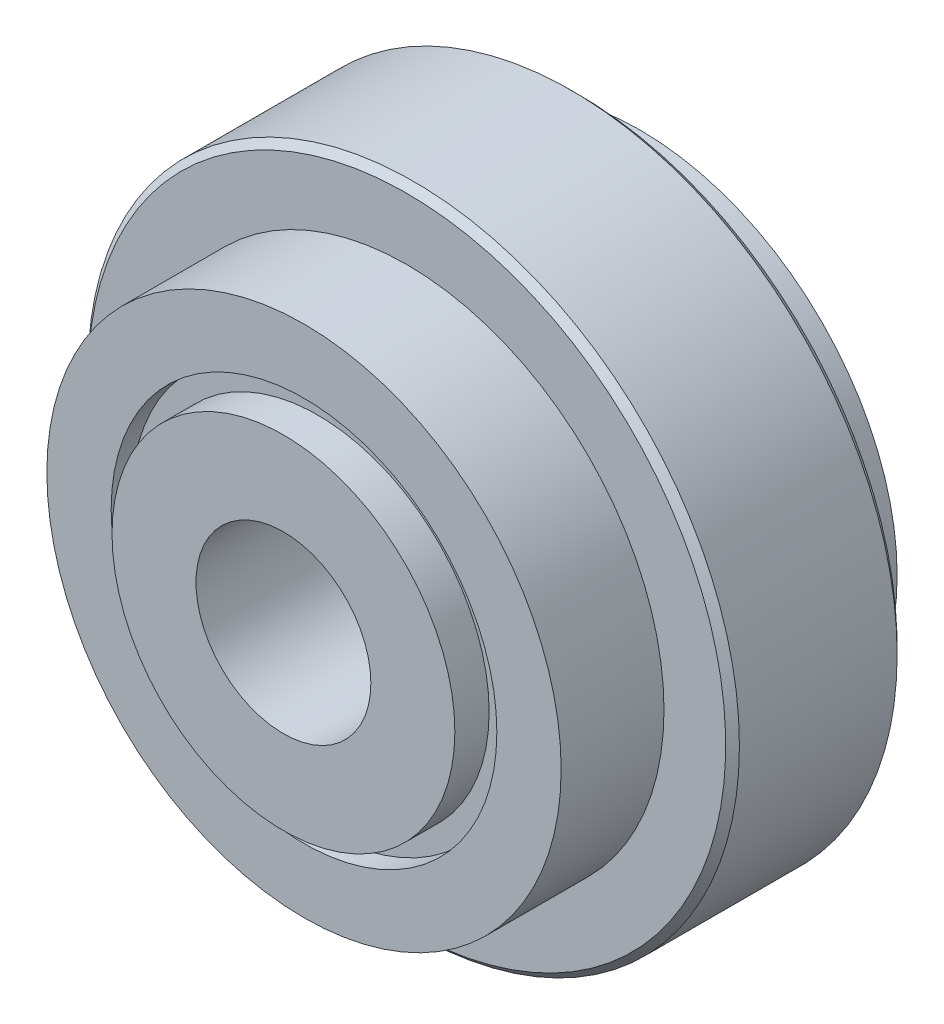
from build123d import *

# Parameters (mm, degrees)
SKETCH3_W = 1
SKETCH3_H = 2.25


with BuildPart() as part:
    # Sketch1 → Revolve1 (revolve)
    with BuildSketch(Plane(origin=(0, 0, 0), x_dir=(0, 0, -1), z_dir=(1, 0, 0)), mode=Mode.PRIVATE) as revolve1_sk:
        with BuildLine():
            Line((-3.8, 3.55), (3.8, 3.55))
            ThreePointArc((3.8, 3.55), (4.153553391, 3.696446609), (4.3, 4.05))
            Line((4.3, 4.05), (4.3, 5.625))
            Line((4.3, 5.625), (4.9, 5.625))
            Line((4.9, 5.625), (4.9, 7.5))
            Line((4.9, 7.5), (3.1, 7.5))
            Line((3.1, 7.5), (3.1, 9.3))
            Line((3.1, 9.3), (2.9, 9.5))
            Line((2.9, 9.5), (-1.7, 9.5))
            Line((-1.7, 9.5), (-1.9, 9.3))
            Line((-1.9, 9.3), (-1.9, 7.5))
            Line((-1.9, 7.5), (-4.9, 7.5))
            Line((-4.9, 7.5), (-4.9, 5.625))
            Line((-4.9, 5.625), (-4.3, 5.625))
            Line((-4.3, 5.625), (-4.3, 4.05))
            ThreePointArc((-4.3, 4.05), (-4.153553391, 3.696446609), (-3.8, 3.55))
        make_face()
    revolve(revolve1_sk.sketch.rotate(Axis((0, 0, -4.9), (0, 0, 1)), 90), axis=Axis((0, 0, -4.9), (0, 0, 1)))


with BuildPart() as body_2:
    # Sketch2 → Revolve2 (revolve)
    with BuildSketch(Plane(origin=(0, 0, 0), x_dir=(0, 0, -1), z_dir=(1, 0, 0)), mode=Mode.PRIVATE) as revolve2_sk:
        Polygon((-5.5, 5), (-4.5, 5), (-4.5, 3.5), (4.5, 3.5), (4.5, 2.55), (-5.5, 2.55), align=None)
    revolve(revolve2_sk.sketch.rotate(Axis((0, 0, 4.9), (0, 0, -1)), 90), axis=Axis((0, 0, 4.9), (0, 0, -1)))


with BuildPart() as body_3:
    # Sketch3 → Revolve3 (revolve)
    with BuildSketch(Plane(origin=(0, 0, 0), x_dir=(0, 0, -1), z_dir=(1, 0, 0)), mode=Mode.PRIVATE) as revolve3_sk:
        with Locations((5, 3.875)):
            Rectangle(SKETCH3_W, SKETCH3_H)
    revolve(revolve3_sk.sketch.rotate(Axis((0, 0, 4.9), (0, 0, -1)), 90), axis=Axis((0, 0, 4.9), (0, 0, -1)))


solid = Compound([part.part, body_2.part, body_3.part])
